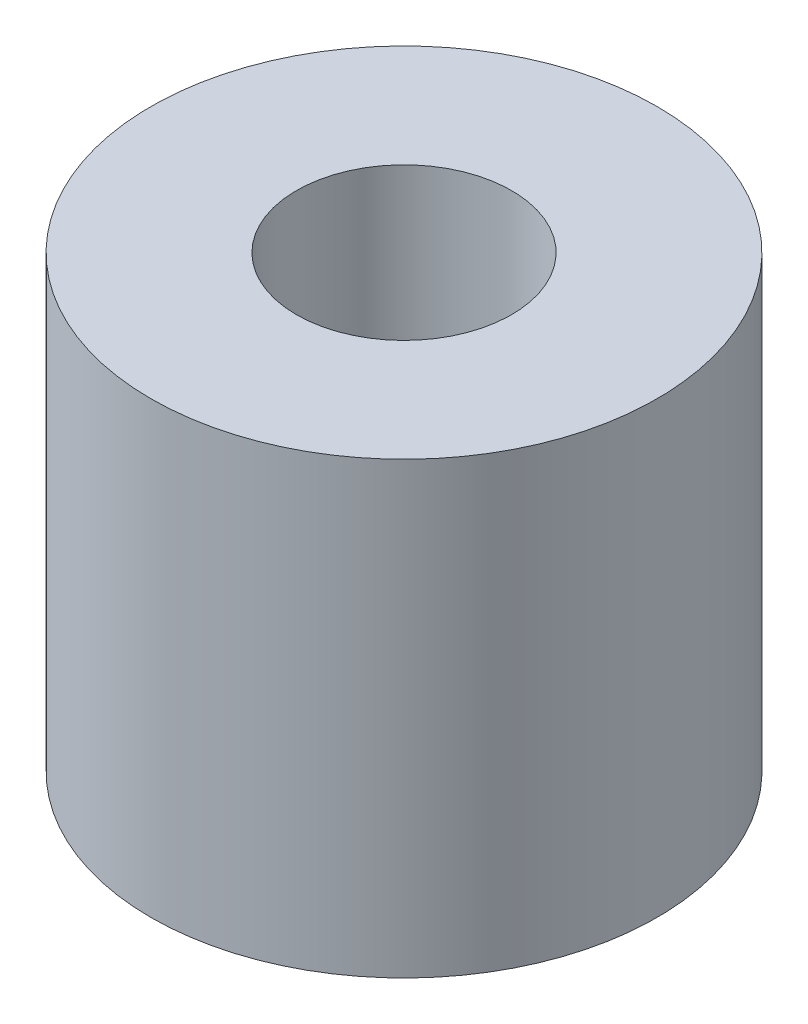
from build123d import *

# Parameters (mm, degrees)
SKETCH1_R           = 4
SKETCH1_R_2         = 1.7
BOSS_EXTRUDE1_DEPTH = 7.1


with BuildPart() as part:
    # Sketch1 → Boss-Extrude1 (new body)
    with BuildSketch(Plane(origin=(0, 0, 0), x_dir=(1, 0, 0), z_dir=(0, 1, 0))):
        Circle(SKETCH1_R)
        Circle(SKETCH1_R_2, mode=Mode.SUBTRACT)
    extrude(amount=BOSS_EXTRUDE1_DEPTH)


solid = part.part
